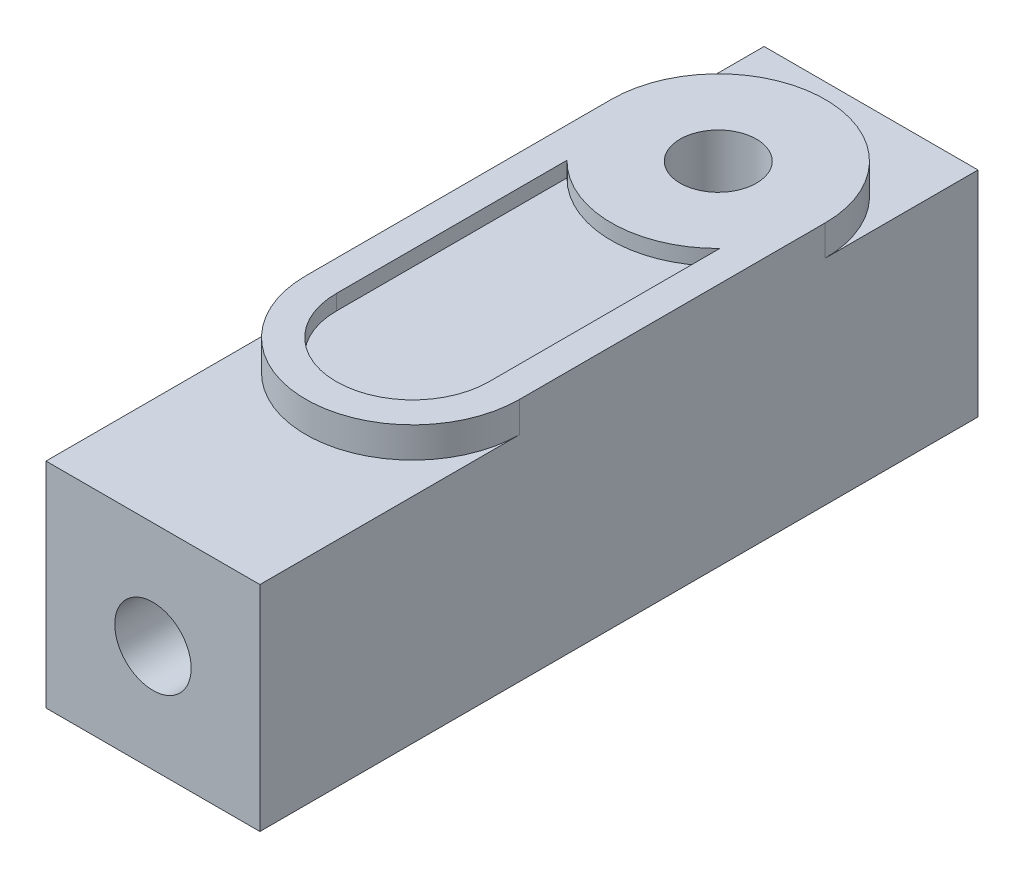
from build123d import *

# Parameters (mm, degrees)
ESQUISSE1_W             = 7
ESQUISSE1_H             = 7
BASE_EXTRUSION_DEPTH    = 23.5
BOSS_EXTRU_1_DEPTH      = 1
ESQUISSE3_R             = 1.25
ENL_V_MAT_EXTRU_1_DEPTH = 9
ENL_V_MAT_EXTRU_2_DEPTH = 0.5
ESQUISSE5_R             = 1.25
ENL_V_MAT_EXTRU_3_DEPTH = 10


with BuildPart() as part:
    # Esquisse1 → Base-Extrusion (new body)
    with BuildSketch(Plane.XY):
        with Locations((3.5, 3.5)):
            Rectangle(ESQUISSE1_W, ESQUISSE1_H)
    extrude(amount=BASE_EXTRUSION_DEPTH)

    # Esquisse2 → Boss.-Extru.1 (add)
    with BuildSketch(Plane(origin=(0, 7, 0), x_dir=(-1, 0, 0), z_dir=(0, 1, 0))):
        with BuildLine():
            Line((0, 5), (0, 15))
            ThreePointArc((0, 15), (-3.5, 18.5), (-7, 15))
            Line((-7, 15), (-7, 5))
            ThreePointArc((-7, 5), (-3.5, 1.5), (0, 5))
        make_face()
    extrude(amount=BOSS_EXTRU_1_DEPTH)

    # Esquisse3 → Enlèv. mat.-Extru.1 (cut, through all)
    with BuildSketch(Plane(origin=(0, 8, 0), x_dir=(-1, 0, 0), z_dir=(0, 1, 0))):
        with Locations((-3.5, 5)):
            Circle(ESQUISSE3_R)
    extrude(amount=-ENL_V_MAT_EXTRU_1_DEPTH, mode=Mode.SUBTRACT)

    # Esquisse4 → Enlèv. mat.-Extru.2 (cut)
    with BuildSketch(Plane(origin=(0, 8, 0), x_dir=(-1, 0, 0), z_dir=(0, 1, 0))):
        with BuildLine():
            Line((-1, 15), (-1, 7.449489743))
            ThreePointArc((-1, 7.449489743), (-3.5, 8.5), (-6, 7.449489743))
            Line((-6, 7.449489743), (-6, 15))
            ThreePointArc((-6, 15), (-3.5, 17.5), (-1, 15))
        make_face()
    extrude(amount=-ENL_V_MAT_EXTRU_2_DEPTH, mode=Mode.SUBTRACT)

    # Esquisse5 → Enlèv. mat.-Extru.3 (cut)
    with BuildSketch(Plane.XY.offset(23.5)):
        with Locations((3.5, 3.5)):
            Circle(ESQUISSE5_R)
    extrude(amount=-ENL_V_MAT_EXTRU_3_DEPTH, mode=Mode.SUBTRACT)


solid = part.part
